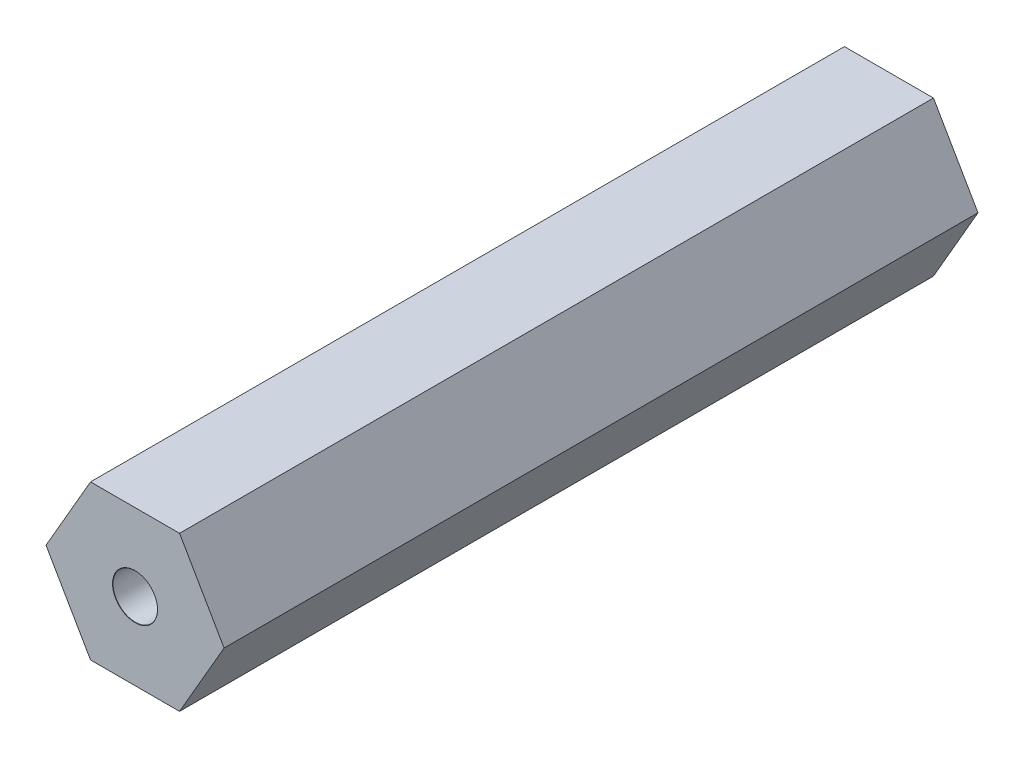
from build123d import *

# Parameters (mm, degrees)
RESSALTO_EXTRUS_O1_DEPTH          = 38.1
CORTE_EXTRUS_O1_START             = -10
CORTE_EXTRUS_O1_DEPTH             = 4.5
FURO_COM_FOLGA_DE_M41_D           = 4.5
FURO_COM_FOLGA_DE_M41_DEPTH       = 10
FURO_COM_FOLGA_DE_M41_CSINK_D     = 4.55
FURO_COM_FOLGA_DE_M41_CSINK_ANGLE = 90


with BuildPart() as part:
    # Esboço1 → Ressalto-extrusão1 (new body, symmetric)
    with BuildSketch(Plane.XY):
        Polygon((-4.5, -7.794228634), (4.5, -7.794228634), (9, 0), (4.5, 7.794228634), (-4.5, 7.794228634), (-9, 0), align=None)
    extrude(amount=RESSALTO_EXTRUS_O1_DEPTH, both=True)

    # Esboço4 → Corte-extrusão1 (cut)
    with BuildSketch(Plane.XY.offset(38.1).offset(CORTE_EXTRUS_O1_START)):
        Polygon((2.165063509, 3.75), (-6.834936491, 3.75), (-9, 0), (-6.834936491, -3.75), (2.165063509, -3.75), (4.330127019, 0), align=None)
    corte_extrus_o1 = extrude(amount=-CORTE_EXTRUS_O1_DEPTH, mode=Mode.SUBTRACT)

    # Furo com folga de M41
    with Locations(Plane.XY.offset(38.1)):
        with Locations((0, 0)):
            furo_com_folga_de_m41 = CounterSinkHole(FURO_COM_FOLGA_DE_M41_D / 2, FURO_COM_FOLGA_DE_M41_CSINK_D / 2, depth=FURO_COM_FOLGA_DE_M41_DEPTH, counter_sink_angle=FURO_COM_FOLGA_DE_M41_CSINK_ANGLE)

    # Espelhar1: Corte-extrusão1, Furo com folga de M41 across plane
    add(corte_extrus_o1.mirror(Plane.XY), mode=Mode.SUBTRACT)
    add(furo_com_folga_de_m41.mirror(Plane.XY), mode=Mode.SUBTRACT)


solid = part.part
